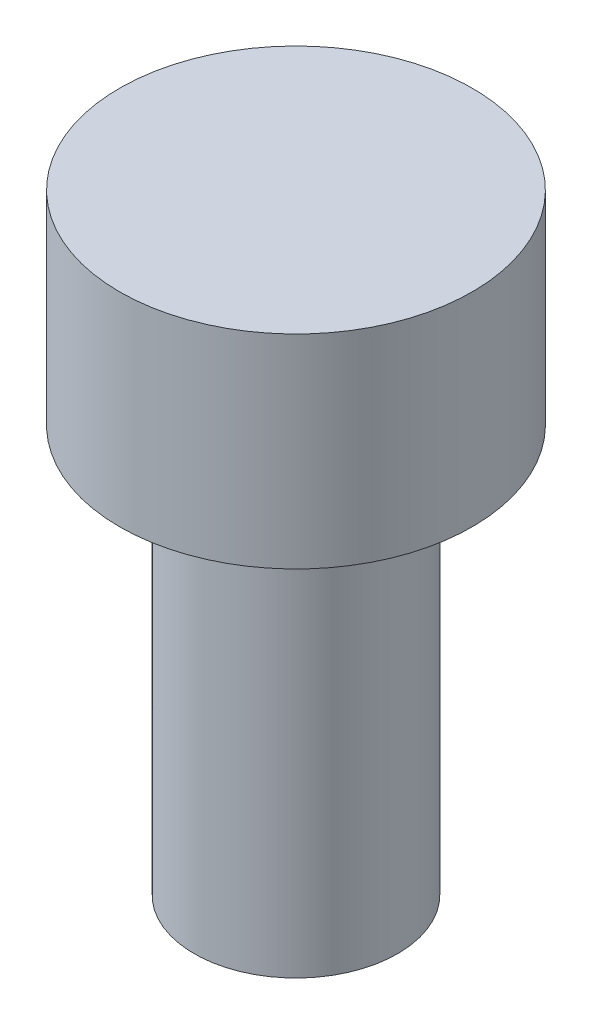
from build123d import *

# Parameters (mm, degrees)
SKETCH1_R           = 2.6
BOSS_EXTRUDE1_DEPTH = 3
SKETCH2_R           = 1.5
BOSS_EXTRUDE2_DEPTH = 6


with BuildPart() as part:
    # Sketch1 → Boss-Extrude1 (new body)
    with BuildSketch(Plane(origin=(0, 0, 0), x_dir=(1, 0, 0), z_dir=(0, 1, 0))):
        Circle(SKETCH1_R)
    extrude(amount=BOSS_EXTRUDE1_DEPTH)

    # Sketch2 → Boss-Extrude2 (add)
    with BuildSketch(Plane.XZ):
        Circle(SKETCH2_R)
    extrude(amount=BOSS_EXTRUDE2_DEPTH)


solid = part.part
